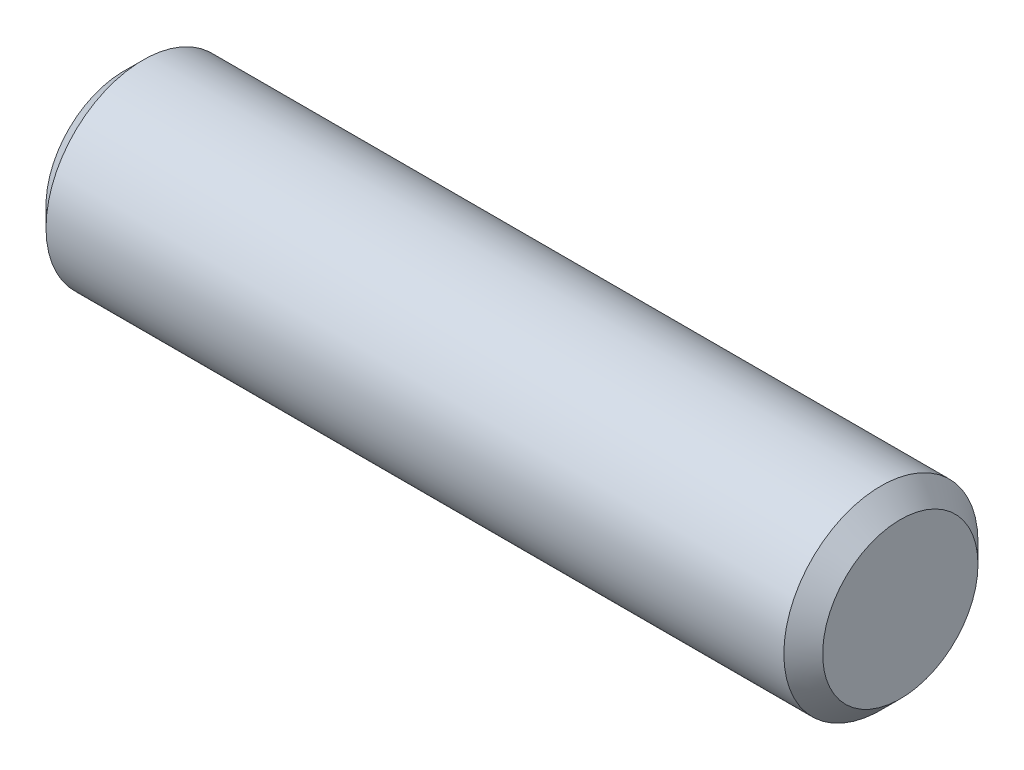
from build123d import *

# Parameters (mm, degrees)
SKETCH2_R           = 2.38125
EXTRUDE1_DEPTH      = 9.525
EXTRUDE1_DEPTH_BACK = 9.525
CHAMFER1_SIZE       = 0.47625


with BuildPart() as part:
    # Sketch2 → Extrude1 (new body, two sides)
    with BuildSketch(Plane(origin=(0, 0, 0), x_dir=(0, 0, -1), z_dir=(1, 0, 0))) as extrude1_sk:
        Circle(SKETCH2_R)
    extrude(amount=EXTRUDE1_DEPTH)
    extrude(extrude1_sk.sketch, amount=-EXTRUDE1_DEPTH_BACK)

    # Chamfer1
    chamfer1_edges = [part.edges().sort_by_distance(p)[0] for p in [
        (-9.525, 0, 2.38125),
        (9.525, 0, 2.38125),
    ]]
    chamfer(chamfer1_edges, length=CHAMFER1_SIZE)


solid = part.part
